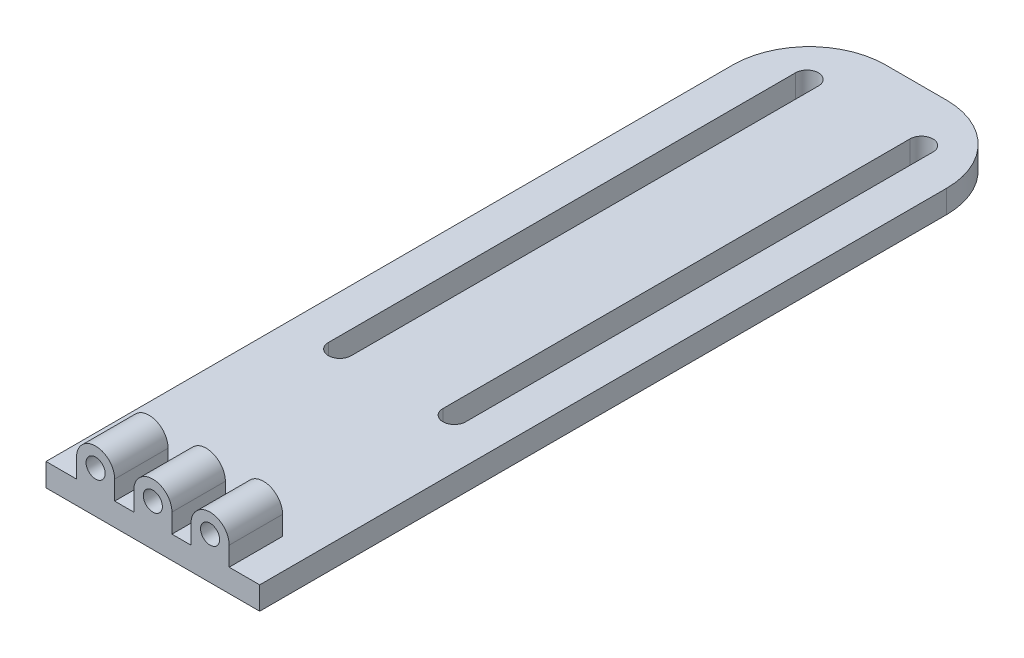
from build123d import *

# Parameters (mm, degrees)
CROQUIS1_W              = 28
CROQUIS1_H              = 100
SALIENTE_EXTRUIR1_DEPTH = 3
CROQUIS2_W              = 28
CROQUIS2_H              = 7
SALIENTE_EXTRUIR2_DEPTH = 5
CORTAR_EXTRUIR2_REACH   = 102
CROQUIS3_R              = 1.25
CORTAR_EXTRUIR3_START   = -7
CORTAR_EXTRUIR3_DEPTH   = 7
CORTAR_EXTRUIR4_DEPTH   = 10
REDONDEO1_R             = 10


with BuildPart() as part:
    # Croquis1 → Saliente-Extruir1 (new body)
    with BuildSketch(Plane(origin=(0, 0, 0), x_dir=(1, 0, 0), z_dir=(0, 1, 0))):
        with Locations((0, 50)):
            Rectangle(CROQUIS1_W, CROQUIS1_H)
    extrude(amount=SALIENTE_EXTRUIR1_DEPTH)

    # Croquis2 → Saliente-Extruir2 (add)
    with BuildSketch(Plane(origin=(0, 3, 0), x_dir=(1, 0, 0), z_dir=(0, 1, 0))):
        with Locations((0, 3.5)):
            Rectangle(CROQUIS2_W, CROQUIS2_H)
    extrude(amount=SALIENTE_EXTRUIR2_DEPTH)

    # Croquis3 → Cortar-Extruir2 (cut, up to next)
    with BuildSketch(Plane.XY, mode=Mode.PRIVATE) as cortar_extruir2_sk1:
        with Locations((-7.5, 5.5)):
            Circle(CROQUIS3_R)
    cortar_extruir2_tool1 = extrude(cortar_extruir2_sk1.sketch, amount=-CORTAR_EXTRUIR2_REACH, mode=Mode.PRIVATE) & part.part
    add(cortar_extruir2_tool1.solids().sort_by_distance((-7.5, 5.5, 0))[0], mode=Mode.SUBTRACT)
    # Croquis3 → Cortar-Extruir2 (cut, up to next)
    with BuildSketch(Plane.XY, mode=Mode.PRIVATE) as cortar_extruir2_sk2:
        with Locations((0, 5.5)):
            Circle(CROQUIS3_R)
    cortar_extruir2_tool2 = extrude(cortar_extruir2_sk2.sketch, amount=-CORTAR_EXTRUIR2_REACH, mode=Mode.PRIVATE) & part.part
    add(cortar_extruir2_tool2.solids().sort_by_distance((0, 5.5, 0))[0], mode=Mode.SUBTRACT)
    # Croquis3 → Cortar-Extruir2 (cut, up to next)
    with BuildSketch(Plane.XY, mode=Mode.PRIVATE) as cortar_extruir2_sk3:
        with Locations((7.5, 5.5)):
            Circle(CROQUIS3_R)
    cortar_extruir2_tool3 = extrude(cortar_extruir2_sk3.sketch, amount=-CORTAR_EXTRUIR2_REACH, mode=Mode.PRIVATE) & part.part
    add(cortar_extruir2_tool3.solids().sort_by_distance((7.5, 5.5, 0))[0], mode=Mode.SUBTRACT)

    # Croquis4 → Cortar-Extruir3 (cut)
    with BuildSketch(Plane.XY.offset(CORTAR_EXTRUIR3_START)):
        with BuildLine():
            Line((-10, 3), (-14, 3))
            Line((-14, 3), (-14, 8))
            Line((-14, 8), (-14, 10.200483226))
            Line((-14, 10.200483226), (14, 10.200483226))
            Line((14, 10.200483226), (14, 8))
            Line((14, 8), (14, 3))
            Line((14, 3), (10, 3))
            Line((10, 3), (10, 5.5))
            ThreePointArc((10, 5.5), (7.5, 8), (5, 5.5))
            Line((5, 5.5), (5, 3))
            Line((5, 3), (2.5, 3))
            Line((2.5, 3), (2.5, 5.5))
            ThreePointArc((2.5, 5.5), (0, 8), (-2.5, 5.5))
            Line((-2.5, 5.5), (-2.5, 3))
            Line((-2.5, 3), (-5, 3))
            Line((-5, 3), (-5, 5.5))
            ThreePointArc((-5, 5.5), (-7.5, 8), (-10, 5.5))
            Line((-10, 5.5), (-10, 3))
        make_face()
    extrude(amount=CORTAR_EXTRUIR3_DEPTH, mode=Mode.SUBTRACT)

    # Croquis5 → Cortar-Extruir4 (cut)
    with BuildSketch(Plane(origin=(0, 3, 0), x_dir=(1, 0, 0), z_dir=(0, 1, 0))):
        with BuildLine():
            Line((-9, 32), (-9, 93.208471881))
            ThreePointArc((-9, 93.208471881), (-7.5, 94.708471881), (-6, 93.208471881))
            Line((-6, 93.208471881), (-6, 32))
            ThreePointArc((-6, 32), (-7.5, 30.5), (-9, 32))
        make_face()
        with BuildLine():
            Line((9, 32), (9, 93.208471881))
            ThreePointArc((9, 93.208471881), (7.5, 94.708471881), (6, 93.208471881))
            Line((6, 93.208471881), (6, 32))
            ThreePointArc((6, 32), (7.5, 30.5), (9, 32))
        make_face()
    extrude(amount=-CORTAR_EXTRUIR4_DEPTH, mode=Mode.SUBTRACT)

    # Redondeo1
    redondeo1_edges = [part.edges().sort_by_distance(p)[0] for p in [
        (-14, 1.5, -100),
        (14, 1.5, -100),
    ]]
    fillet(redondeo1_edges, radius=REDONDEO1_R)


solid = part.part
